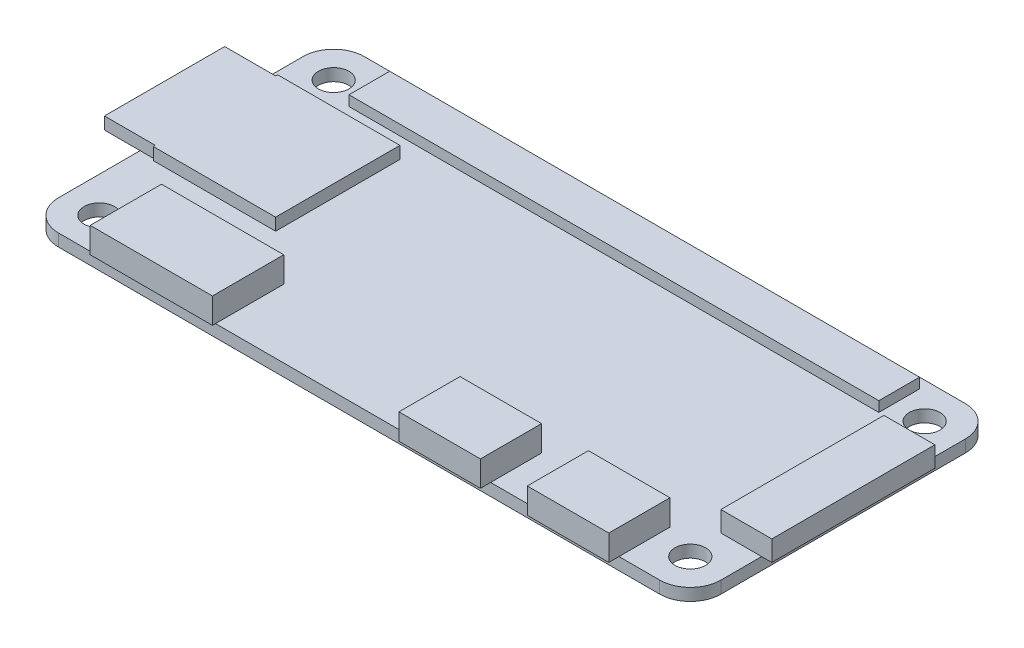
from build123d import *

# Parameters (mm, degrees)
SKETCH1_W           = 65
SKETCH1_H           = 30
BOSS_EXTRUDE1_DEPTH = 1.2
SKETCH2_R           = 1.5
CUT_EXTRUDE1_DEPTH  = 2.2
FILLET1_R           = 3
SKETCH3_W           = 12
SKETCH3_H           = 12.2
BOSS_EXTRUDE2_DEPTH = 1.2
SKETCH4_W           = 11.8
SKETCH4_H           = 1.2
BOSS_EXTRUDE3_DEPTH = 5
SKETCH5_W           = 12
SKETCH5_H           = 7
BOSS_EXTRUDE4_DEPTH = 2.5
SKETCH6_W           = 8
SKETCH6_H           = 6
BOSS_EXTRUDE5_DEPTH = 2.5
SKETCH7_W           = 5
SKETCH7_H           = 16
BOSS_EXTRUDE6_DEPTH = 2
SKETCH8_W           = 52
SKETCH8_H           = 4
BOSS_EXTRUDE7_DEPTH = 1


with BuildPart() as part:
    # Sketch1 → Boss-Extrude1 (new body)
    with BuildSketch(Plane(origin=(0, 0, 0), x_dir=(1, 0, 0), z_dir=(0, 1, 0))):
        with Locations((32.5, -15)):
            Rectangle(SKETCH1_W, SKETCH1_H)
    extrude(amount=BOSS_EXTRUDE1_DEPTH)

    # Sketch2 → Cut-Extrude1 (cut, through all)
    with BuildSketch(Plane(origin=(0, 1.2, 0), x_dir=(1, 0, 0), z_dir=(0, 1, 0))):
        with Locations((3.5, -26.5)):
            Circle(SKETCH2_R)
        with Locations((61.5, -26.5)):
            Circle(SKETCH2_R)
        with Locations((61.5, -3.5)):
            Circle(SKETCH2_R)
        with Locations((3.5, -3.5)):
            Circle(SKETCH2_R)
    extrude(amount=-CUT_EXTRUDE1_DEPTH, mode=Mode.SUBTRACT)

    # Fillet1
    fillet1_edges = [part.edges().sort_by_distance(p)[0] for p in [
        (0, 0.6, 0),
        (65, 0.6, 0),
        (65, 0.6, 30),
        (0, 0.6, 30),
    ]]
    fillet(fillet1_edges, radius=FILLET1_R)

    # Sketch3 → Boss-Extrude2 (add)
    with BuildSketch(Plane(origin=(0, 1.2, 0), x_dir=(1, 0, 0), z_dir=(0, 1, 0))):
        with Locations((7.5, -13.1)):
            Rectangle(SKETCH3_W, SKETCH3_H)
    extrude(amount=BOSS_EXTRUDE2_DEPTH)

    # Sketch4 → Boss-Extrude3 (add)
    with BuildSketch(Plane.ZY.offset(-1.5)):
        with Locations((13.1, 1.8)):
            Rectangle(SKETCH4_W, SKETCH4_H)
    extrude(amount=BOSS_EXTRUDE3_DEPTH)

    # Sketch5 → Boss-Extrude4 (add)
    with BuildSketch(Plane(origin=(0, 1.2, 0), x_dir=(1, 0, 0), z_dir=(0, 1, 0))):
        with Locations((12.4, -26.8)):
            Rectangle(SKETCH5_W, SKETCH5_H)
    extrude(amount=BOSS_EXTRUDE4_DEPTH)

    # Sketch6 → Boss-Extrude5 (add)
    with BuildSketch(Plane(origin=(0, 1.2, 0), x_dir=(1, 0, 0), z_dir=(0, 1, 0))):
        with Locations((41.4, -28)):
            Rectangle(SKETCH6_W, SKETCH6_H)
        with Locations((54, -28)):
            Rectangle(SKETCH6_W, SKETCH6_H)
    extrude(amount=BOSS_EXTRUDE5_DEPTH)

    # Sketch7 → Boss-Extrude6 (add)
    with BuildSketch(Plane(origin=(0, 1.2, 0), x_dir=(1, 0, 0), z_dir=(0, 1, 0))):
        with Locations((63.5, -15)):
            Rectangle(SKETCH7_W, SKETCH7_H)
    extrude(amount=BOSS_EXTRUDE6_DEPTH)

    # Sketch8 → Boss-Extrude7 (add)
    with BuildSketch(Plane(origin=(0, 1.2, 0), x_dir=(1, 0, 0), z_dir=(0, 1, 0))):
        with Locations((32.5, -3)):
            Rectangle(SKETCH8_W, SKETCH8_H)
    extrude(amount=BOSS_EXTRUDE7_DEPTH)


solid = part.part
